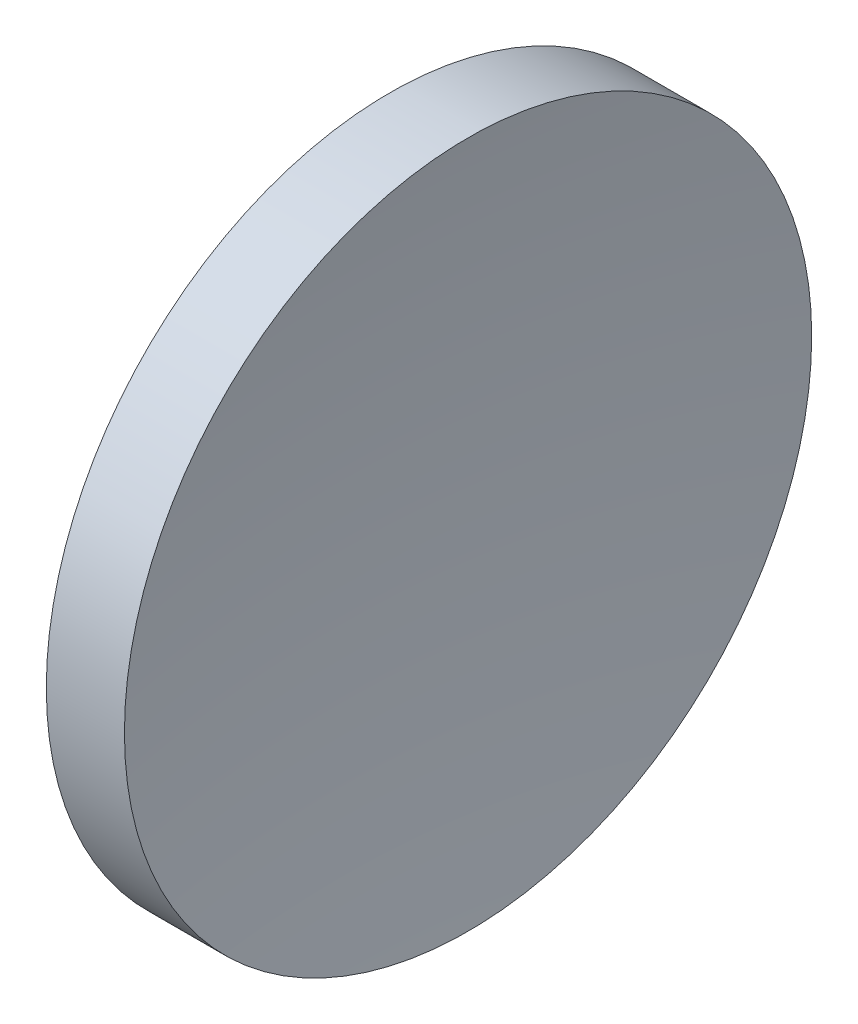
from build123d import *


with BuildPart() as part:
    # 草图1 → 旋转1 (revolve)
    with BuildSketch(Plane.XY, mode=Mode.PRIVATE) as revolve_1_sk:
        with BuildLine():
            Line((119.362930792, 71.193989087), (119.362930792, 83.893989087))
            Line((119.362930792, 83.893989087), (122.250102105, 83.893989087))
            ThreePointArc((122.250102105, 83.893989087), (121.585853552, 77.559403716), (121.362930792, 71.193989087))
            Line((121.362930792, 71.193989087), (119.362930792, 71.193989087))
        make_face()
    revolve(revolve_1_sk.sketch.rotate(Axis((111.955229758, 71.193989087, 0), (1, 0, 0)), 90), axis=Axis((111.955229758, 71.193989087, 0), (1, 0, 0)))  # turned: the seam where the file's is


solid = part.part
